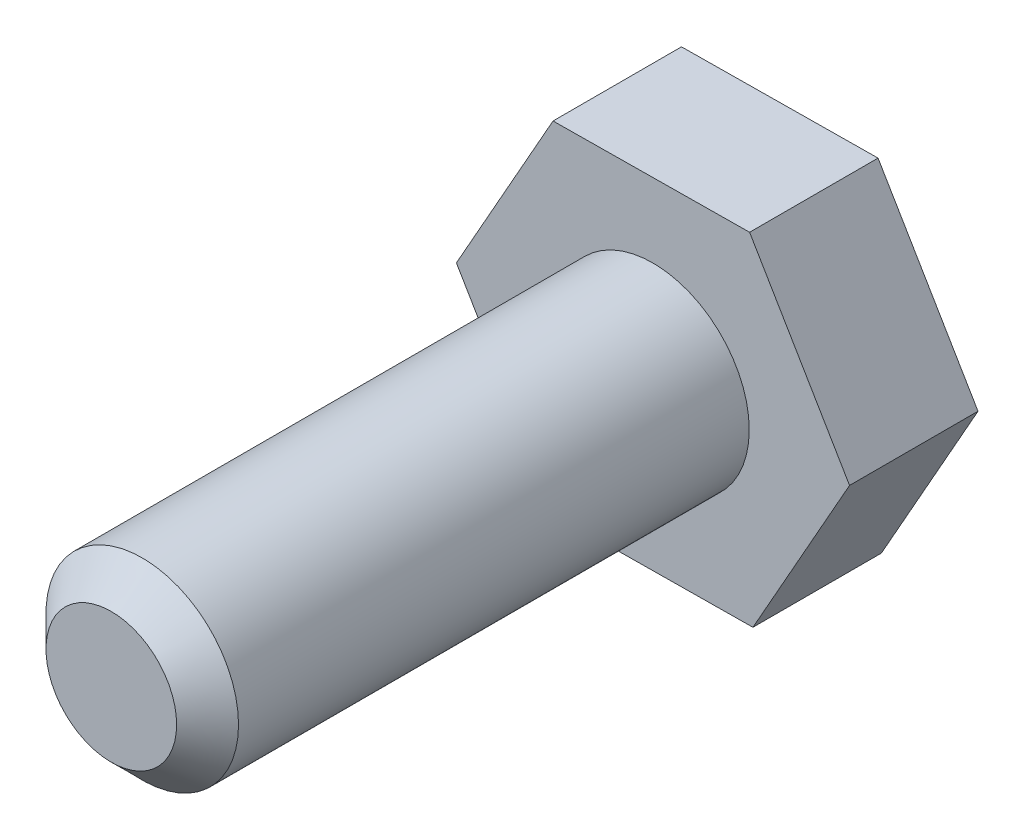
from build123d import *

# Parameters (mm, degrees)
DODANIE_WYCI_GNI_CIE1_DEPTH = 4.15
SZKIC2_R                    = 3.11
DODANIE_WYCI_GNI_CIE2_DEPTH = 17.5
SFAZOWANIE1_SIZE            = 1


with BuildPart() as part:
    # Szkic1 → Dodanie-wyciągnięcie1 (new body)
    with BuildSketch(Plane.XY):
        Polygon((-3.229086971, 5.468668089), (-6.350548975, -0.062137304), (-3.121462004, -5.530805393), (3.229086971, -5.468668089), (6.350548975, 0.062137304), (3.121462004, 5.530805393), align=None)
    extrude(amount=DODANIE_WYCI_GNI_CIE1_DEPTH)

    # Szkic2 → Dodanie-wyciągnięcie2 (add)
    with BuildSketch(Plane.XY.offset(4.15)):
        Circle(SZKIC2_R)
    extrude(amount=DODANIE_WYCI_GNI_CIE2_DEPTH)

    # Sfazowanie1
    sfazowanie1_edges = [part.edges().sort_by_distance(p)[0] for p in [
        (-3.11, 0, 21.65),
    ]]
    chamfer(sfazowanie1_edges, length=SFAZOWANIE1_SIZE)


solid = part.part
